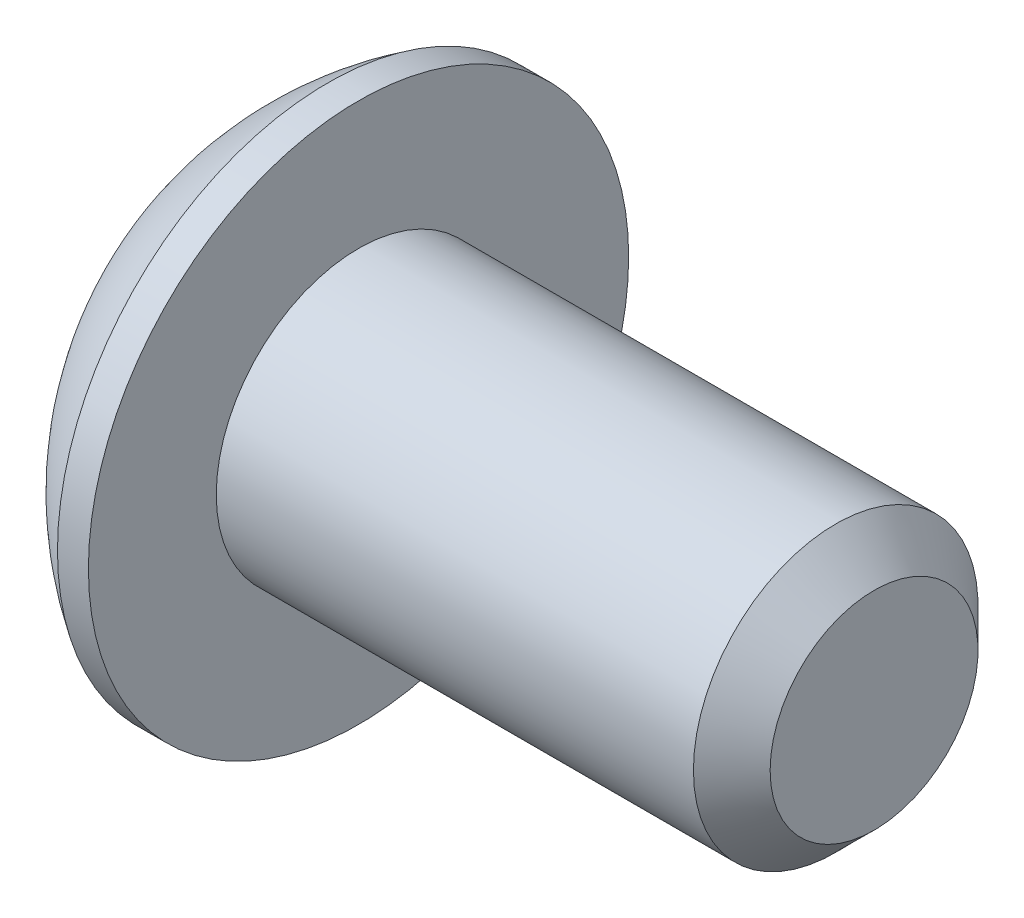
from build123d import *

# Parameters (mm, degrees)
HEX_2_DEPTH = 1.1176


with BuildPart() as part:
    # BodySke → BaseBody (revolve)
    with BuildSketch(Plane.XY):
        with BuildLine():
            Line((8.2042, 0), (8.2042, 1.28016))
            Line((8.2042, 1.28016), (7.73176, 1.7526))
            Line((7.73176, 1.7526), (1.8542, 1.7526))
            Line((1.8542, 1.7526), (1.8542, 3.3274))
            Line((1.8542, 3.3274), (1.4732, 3.3274))
            ThreePointArc((1.4732, 3.3274), (0.616396771, 2.601989501), (0, 1.6637))
            Line((0, 1.6637), (0, 0))
            Line((0, 0), (8.2042, 0))
        make_face()
    revolve(axis=Axis((0, 0, 0), (1, 0, 0)))

    # Sketch2 → PreBroach (revolve, cut)
    with BuildSketch(Plane.XY):
        Polygon((0, 0.9906), (1.1176, 0.9906), (1.689523177, 0), (0, 0), align=None)
    revolve(axis=Axis((0, 0, 0), (1, 0, 0)), mode=Mode.SUBTRACT)

    # Sketch3 → Hex 2 (cut)
    with BuildSketch(Plane(origin=(0, 0, 0), x_dir=(0, 0, -1), z_dir=(1, 0, 0))):
        Polygon((-0.9906, -0.571923177), (-0.9906, 0.571923177), (0, 1.143846353), (0.9906, 0.571923177), (0.9906, -0.571923177), (0, -1.143846353), align=None)
    extrude(amount=HEX_2_DEPTH, mode=Mode.SUBTRACT)


solid = part.part
